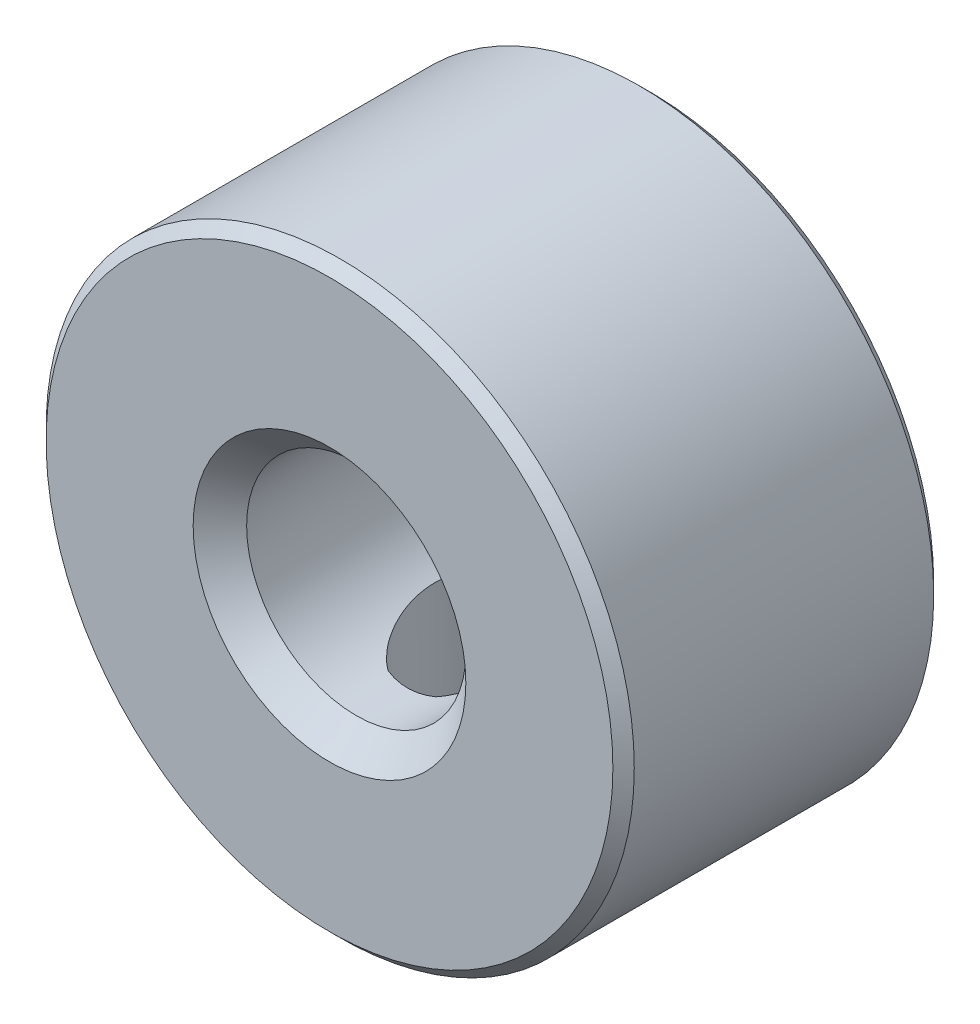
from build123d import *

# Parameters (mm, degrees)
SKETCH1_R                 = 5.5
SKETCH1_R_2               = 2.05
BOSS_EXTRUDE1_DEPTH       = 6
CHAMFER1_SIZE             = 0.5
M4X0_7_TAPPED_HOLE1_D     = 3.3
M4X0_7_TAPPED_HOLE1_DEPTH = 3.5
M4X0_7_TAPPED_HOLE1_TIP   = 0.991420021
CHAMFER2_SIZE             = 0.2


with BuildPart() as part:
    # Sketch1 → Boss-Extrude1 (new body)
    with BuildSketch(Plane.XY):
        Circle(SKETCH1_R)
        Circle(SKETCH1_R_2, mode=Mode.SUBTRACT)
    extrude(amount=BOSS_EXTRUDE1_DEPTH)

    # Chamfer1
    chamfer1_edges = [part.edges().sort_by_distance(p)[0] for p in [
        (-2.05, 0, 0),
        (-2.05, 0, 6),
    ]]
    chamfer(chamfer1_edges, length=CHAMFER1_SIZE)

    # M4x0.7 Tapped Hole1
    with Locations(Plane(origin=(0.156712009, -5.497766942, 2.924685325), x_dir=(-0.999593989, -0.028493093, 0), z_dir=(0.028493093, -0.999593989, 0))):
        with Locations((0, 0)):
            Hole(M4X0_7_TAPPED_HOLE1_D / 2, depth=M4X0_7_TAPPED_HOLE1_DEPTH)
            with Locations((0, 0, -(M4X0_7_TAPPED_HOLE1_DEPTH + M4X0_7_TAPPED_HOLE1_TIP / 2))):  # 118° drill point
                Cone(0, M4X0_7_TAPPED_HOLE1_D / 2, M4X0_7_TAPPED_HOLE1_TIP, mode=Mode.SUBTRACT)

    # Chamfer2
    chamfer2_edges = [part.edges().sort_by_distance(p)[0] for p in [
        (-5.5, 0, 0),
        (-5.5, 0, 6),
    ]]
    chamfer(chamfer2_edges, length=CHAMFER2_SIZE)


solid = part.part
